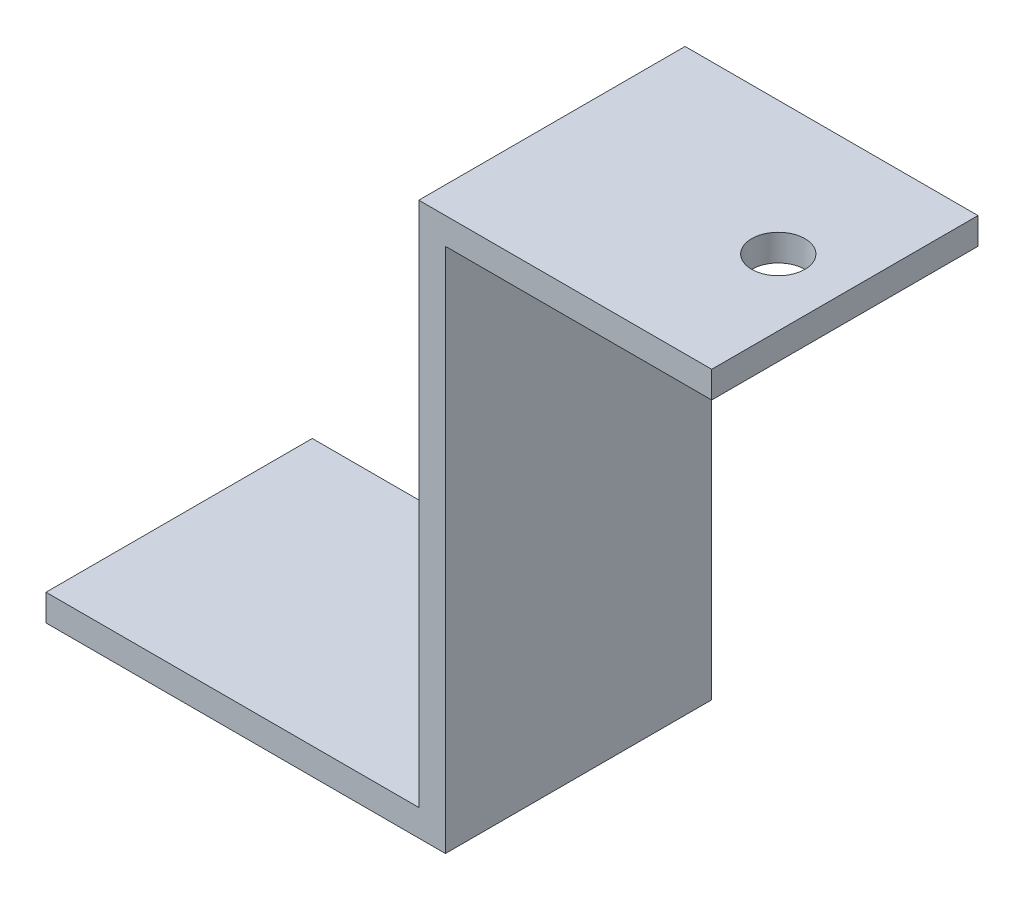
from build123d import *

# Parameters (mm, degrees)
EXTRUDE_1_DEPTH     = 20
SKETCH_2_R          = 2
CUT_EXTRUDE_1_DEPTH = 20


with BuildPart() as part:
    # 草图1 → 凸台-拉伸1 (new body)
    with BuildSketch(Plane.XY):
        Polygon((-17.175607408, 38.860314389), (-7.175607408, 38.860314389), (2.824392592, 38.860314389), (2.824392592, 36.860314389), (-17.175607408, 36.860314389), (-17.175607408, -0.639685611), (-17.175607408, -2.639685611), (-47.175607408, -2.639685611), (-47.175607408, -0.639685611), (-19.175607408, -0.639685611), (-19.175607408, 38.860314389), align=None)
    extrude(amount=EXTRUDE_1_DEPTH)

    # 草图2 → 切除-拉伸1 (cut)
    with BuildSketch(Plane(origin=(0, 38.860314389, 0), x_dir=(1, 0, 0), z_dir=(0, 1, 0))):
        with Locations((-2.175607408, -10)):
            Circle(SKETCH_2_R)
    extrude(amount=-CUT_EXTRUDE_1_DEPTH, mode=Mode.SUBTRACT)


solid = part.part
